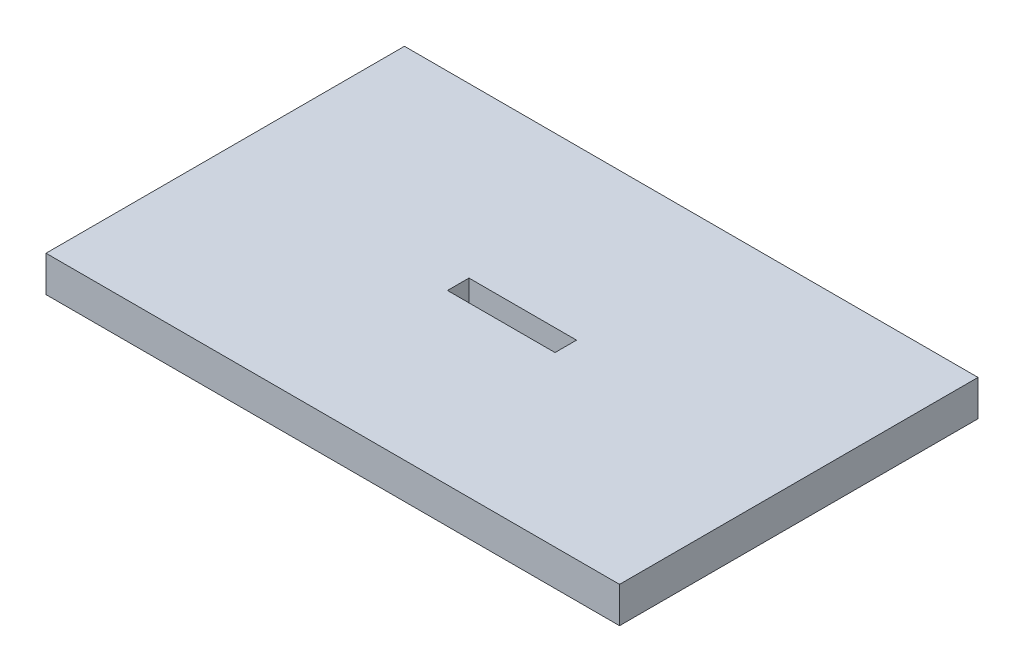
from build123d import *

# Parameters (mm, degrees)
SKETCH_1_W      = 160
SKETCH_1_H      = 100
SKETCH_1_W_2    = 30
SKETCH_1_H_2    = 6
EXTRUDE_1_DEPTH = 10


with BuildPart() as part:
    # Эскиз1 → Бобышка-Вытянуть1 (new body)
    with BuildSketch(Plane(origin=(0, 0, 0), x_dir=(1, 0, 0), z_dir=(0, 1, 0))):
        Rectangle(SKETCH_1_W, SKETCH_1_H)
        Rectangle(SKETCH_1_W_2, SKETCH_1_H_2, mode=Mode.SUBTRACT)
    extrude(amount=EXTRUDE_1_DEPTH)


solid = part.part
